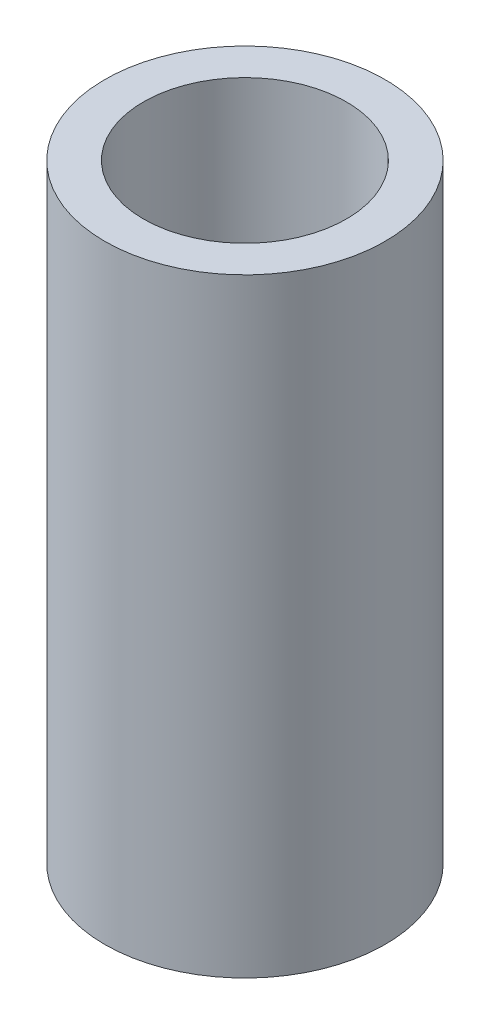
from build123d import *

# Parameters (mm, degrees)
ESBO_O1_R                = 29
ESBO_O1_R_2              = 21
RESSALTO_EXTRUS_O1_DEPTH = 63


with BuildPart() as part:
    # Esboço1 → Ressalto-extrusão1 (new body, symmetric)
    with BuildSketch(Plane(origin=(0, 0, 0), x_dir=(1, 0, 0), z_dir=(0, 1, 0))):
        with Locations(Location((0, 0, 0), (0, 0, 270))):  # turned: the seam where the file's is
            Circle(ESBO_O1_R)
        with Locations(Location((0, 0, 0), (0, 0, 270))):  # turned: the seam where the file's is
            Circle(ESBO_O1_R_2, mode=Mode.SUBTRACT)
    extrude(amount=RESSALTO_EXTRUS_O1_DEPTH, both=True)


solid = part.part
